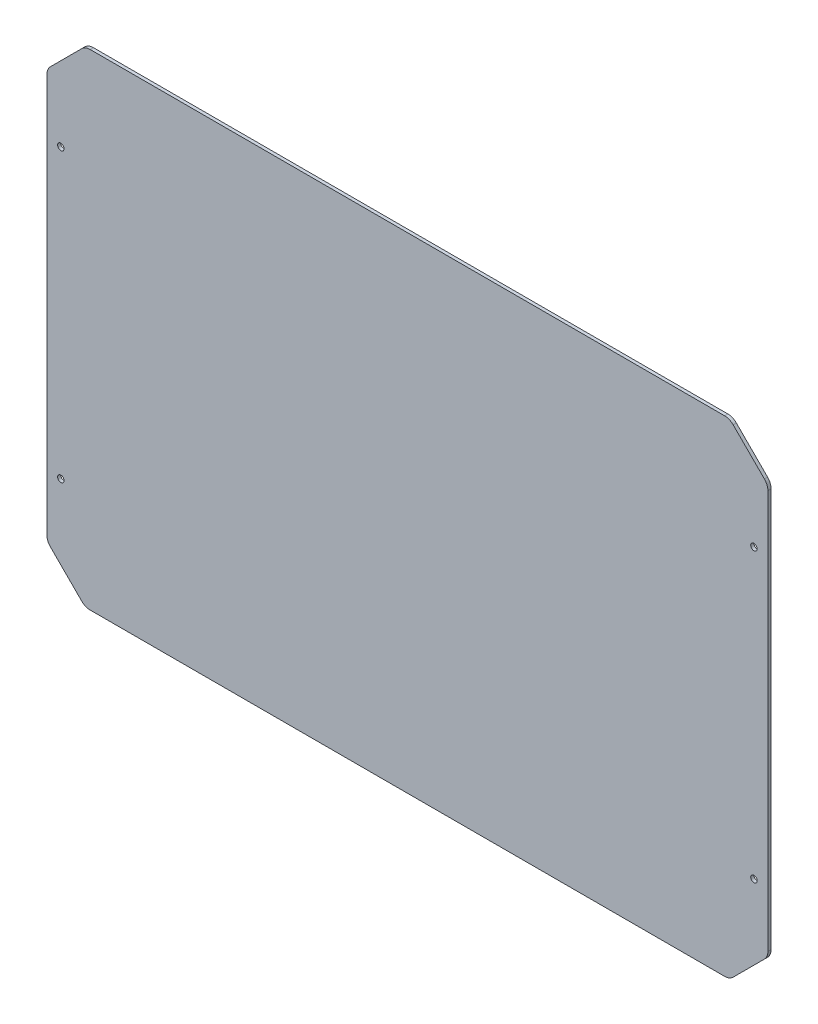
from build123d import *

# Parameters (mm, degrees)
SKETCH2_R           = 4.05
BOSS_EXTRUDE1_DEPTH = 4
FILLET1_R           = 15


with BuildPart() as part:
    # Sketch2 → Boss-Extrude1 (new body)
    with BuildSketch(Plane.XY):
        Polygon((-451.5, 256), (-451.5, -256), (-403.5, -304), (403.5, -304), (451.5, -256), (451.5, 256), (403.5, 304), (-403.5, 304), align=None)
        with Locations((-434, 180)):
            Circle(SKETCH2_R, mode=Mode.SUBTRACT)
        with Locations((-434, -180)):
            Circle(SKETCH2_R, mode=Mode.SUBTRACT)
        with Locations((434, -180)):
            Circle(SKETCH2_R, mode=Mode.SUBTRACT)
        with Locations((434, 180)):
            Circle(SKETCH2_R, mode=Mode.SUBTRACT)
    extrude(amount=BOSS_EXTRUDE1_DEPTH)

    # Fillet1
    fillet1_edges = [part.edges().sort_by_distance(p)[0] for p in [
        (-451.5, -256, 2),
        (-451.5, 256, 2),
        (-403.5, 304, 2),
        (403.5, 304, 2),
        (451.5, 256, 2),
        (451.5, -256, 2),
        (403.5, -304, 2),
        (-403.5, -304, 2),
    ]]
    fillet(fillet1_edges, radius=FILLET1_R)


solid = part.part
